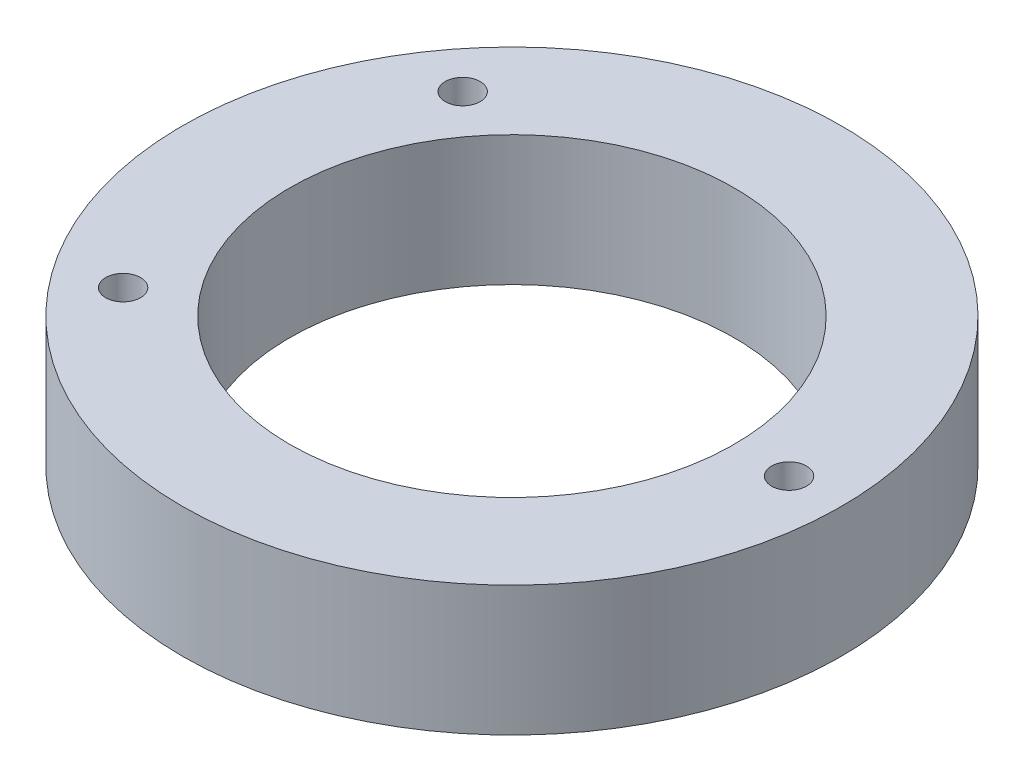
from build123d import *

# Parameters (mm, degrees)
SKETCH2_R           = 33
SKETCH2_R_2         = 22.25
SKETCH2_R_3         = 1.75
BOSS_EXTRUDE1_DEPTH = 13


with BuildPart() as part:
    # Sketch2 → Boss-Extrude1 (new body)
    with BuildSketch(Plane(origin=(0, 0, 0), x_dir=(1, 0, 0), z_dir=(0, 1, 0))):
        Circle(SKETCH2_R)
        Circle(SKETCH2_R_2, mode=Mode.SUBTRACT)
        with Locations((-21.932737229, 17.000515805)):
            Circle(SKETCH2_R_3, mode=Mode.SUBTRACT)
        with Locations((-21.932737229, -17.000515805)):
            Circle(SKETCH2_R_3, mode=Mode.SUBTRACT)
        with Locations((27.75, 0)):
            Circle(SKETCH2_R_3, mode=Mode.SUBTRACT)
    extrude(amount=BOSS_EXTRUDE1_DEPTH)


solid = part.part
